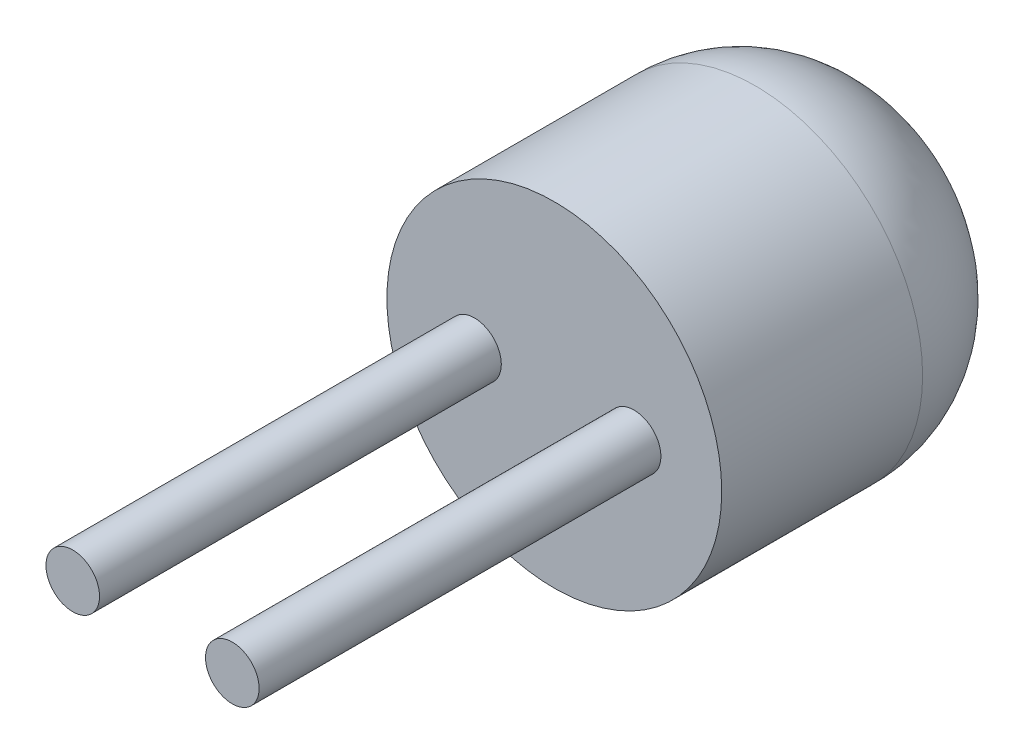
from build123d import *

# Parameters (mm, degrees)
SKETCH1_R           = 2.5
BOSS_EXTRUDE1_DEPTH = 5
SKETCH2_R           = 0.4
BOSS_EXTRUDE2_DEPTH = 6
FILLET1_R           = 2


with BuildPart() as part:
    # Sketch1 → Boss-Extrude1 (new body)
    with BuildSketch(Plane.XY):
        with Locations((-53, 47)):
            Circle(SKETCH1_R)
    extrude(amount=-BOSS_EXTRUDE1_DEPTH)

    # Sketch2 → Boss-Extrude2 (add)
    with BuildSketch(Plane.XY):
        with Locations((-54.191552133, 47)):
            Circle(SKETCH2_R)
        with Locations((-51.808447867, 47)):
            Circle(SKETCH2_R)
    extrude(amount=BOSS_EXTRUDE2_DEPTH)

    # Fillet1
    fillet1_edges = [part.edges().sort_by_distance(p)[0] for p in [
        (-55.5, 47, -5),
    ]]
    fillet(fillet1_edges, radius=FILLET1_R)


solid = part.part
